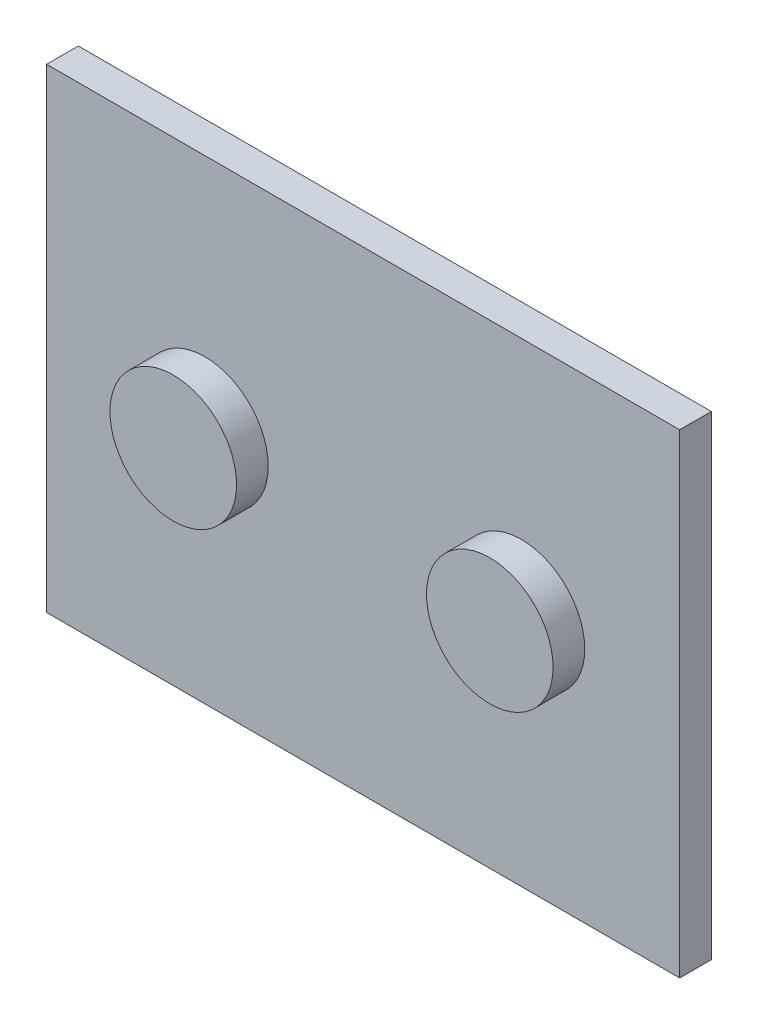
from build123d import *

# Parameters (mm, degrees)
SKETCH1_W           = 200
SKETCH1_H           = 150
BOSS_EXTRUDE2_DEPTH = 10
SKETCH2_R           = 20
BOSS_EXTRUDE3_DEPTH = 10


with BuildPart() as part:
    # Sketch1 → Boss-Extrude2 (new body)
    with BuildSketch(Plane.XY):
        with Locations((-1.369011051, -5.030905367)):
            Rectangle(SKETCH1_W, SKETCH1_H)
    extrude(amount=BOSS_EXTRUDE2_DEPTH)

    # Sketch2 → Boss-Extrude3 (add)
    with BuildSketch(Plane.XY.offset(10)):
        with Locations((-51.369011051, -5.030905367)):
            Circle(SKETCH2_R)
        with Locations((48.630988949, -5.030905367)):
            Circle(SKETCH2_R)
    extrude(amount=BOSS_EXTRUDE3_DEPTH)


solid = part.part
